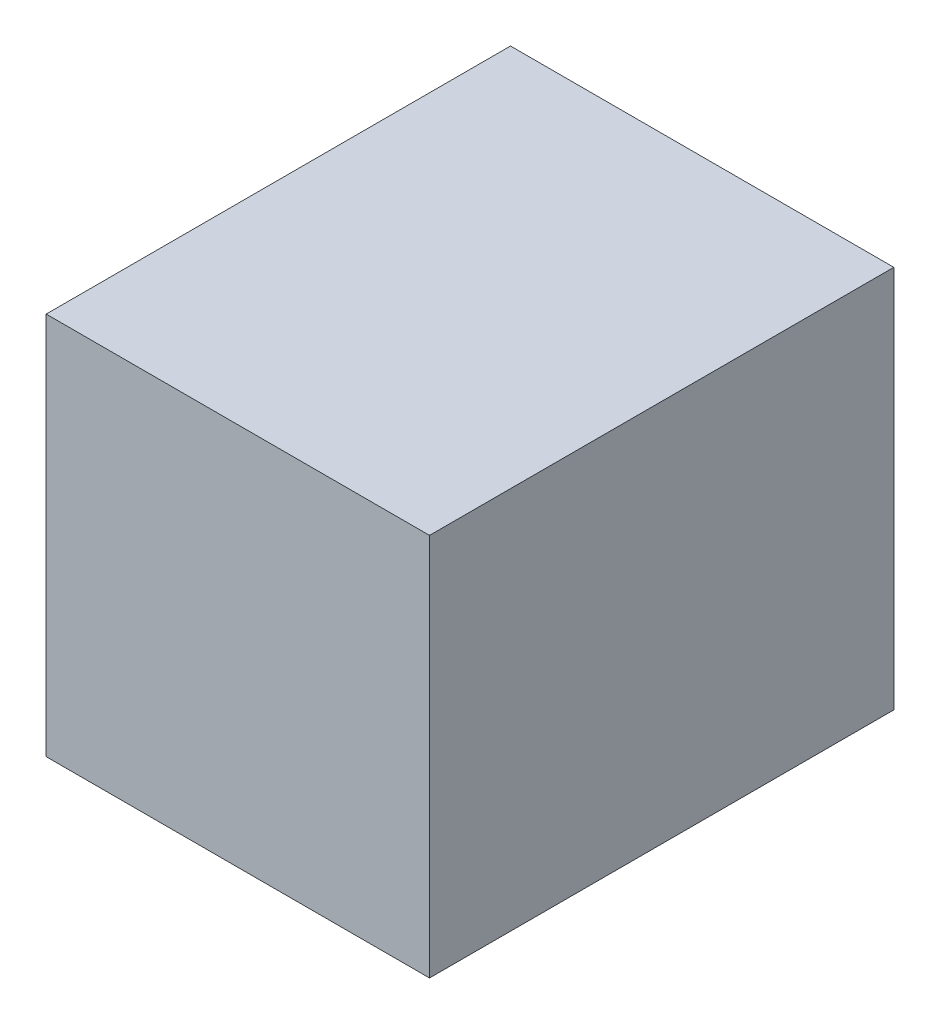
from build123d import *

# Parameters (mm, degrees)
SKETCH1_W           = 101.6
SKETCH1_H           = 101.6
BOSS_EXTRUDE1_DEPTH = 123.063


with BuildPart() as part:
    # Sketch1 → Boss-Extrude1 (new body)
    with BuildSketch(Plane.XY):
        with Locations((50.8, 50.8)):
            Rectangle(SKETCH1_W, SKETCH1_H)
    extrude(amount=BOSS_EXTRUDE1_DEPTH)


solid = part.part
